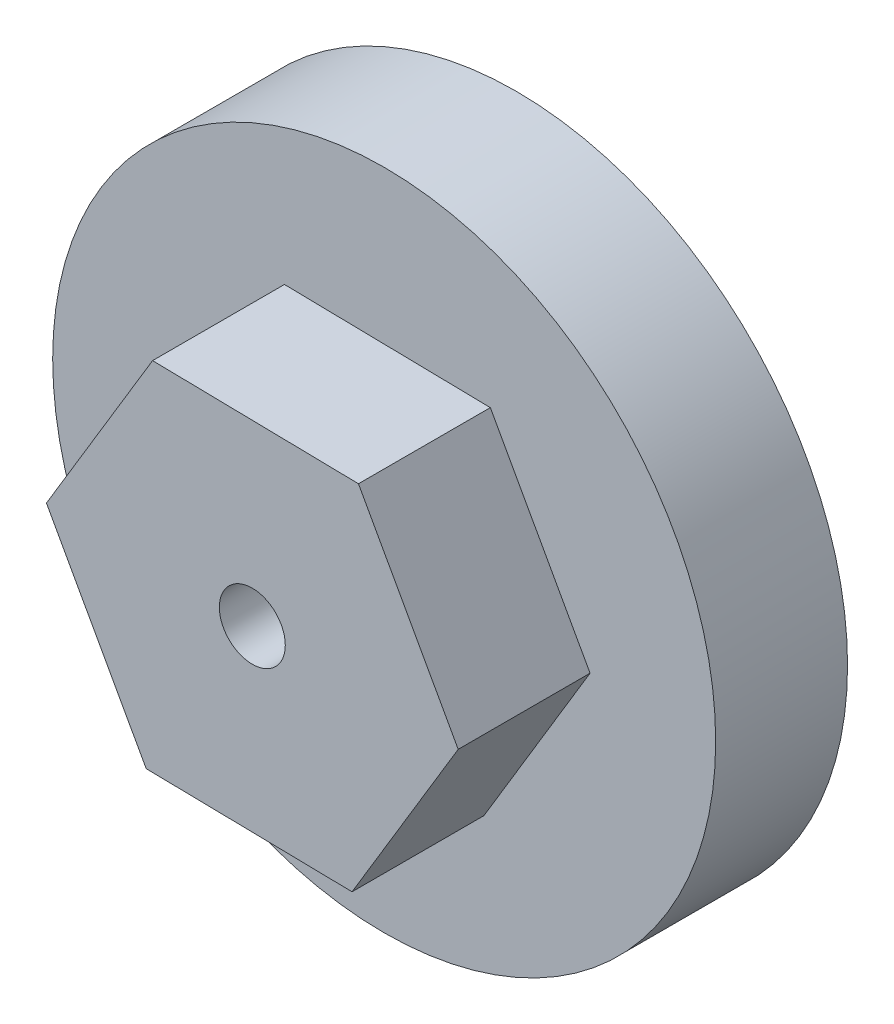
from build123d import *

# Parameters (mm, degrees)
SKETCH1_R           = 25.139311184
BOSS_EXTRUDE1_DEPTH = 10
SKETCH1_3_R         = 2.5
BOSS_EXTRUDE2_DEPTH = 20


with BuildPart() as part:
    # Sketch1 → Boss-Extrude1 (new body)
    with BuildSketch(Plane.XY):
        Circle(SKETCH1_R)
        Polygon((-7.563031623, 13.660780721), (8.049067329, 13.380167876), (15.612098952, -0.280612845), (7.563031623, -13.660780721), (-8.049067329, -13.380167876), (-15.612098952, 0.280612845), align=None, mode=Mode.SUBTRACT)
    extrude(amount=BOSS_EXTRUDE1_DEPTH)

    # Sketch1_3 → Boss-Extrude2 (add)
    with BuildSketch(Plane.XY):
        Polygon((15.612098952, -0.280612845), (8.049067329, 13.380167876), (-7.563031623, 13.660780721), (-15.612098952, 0.280612845), (-8.049067329, -13.380167876), (7.563031623, -13.660780721), align=None)
        Circle(SKETCH1_3_R, mode=Mode.SUBTRACT)
    extrude(amount=BOSS_EXTRUDE2_DEPTH)


solid = part.part
